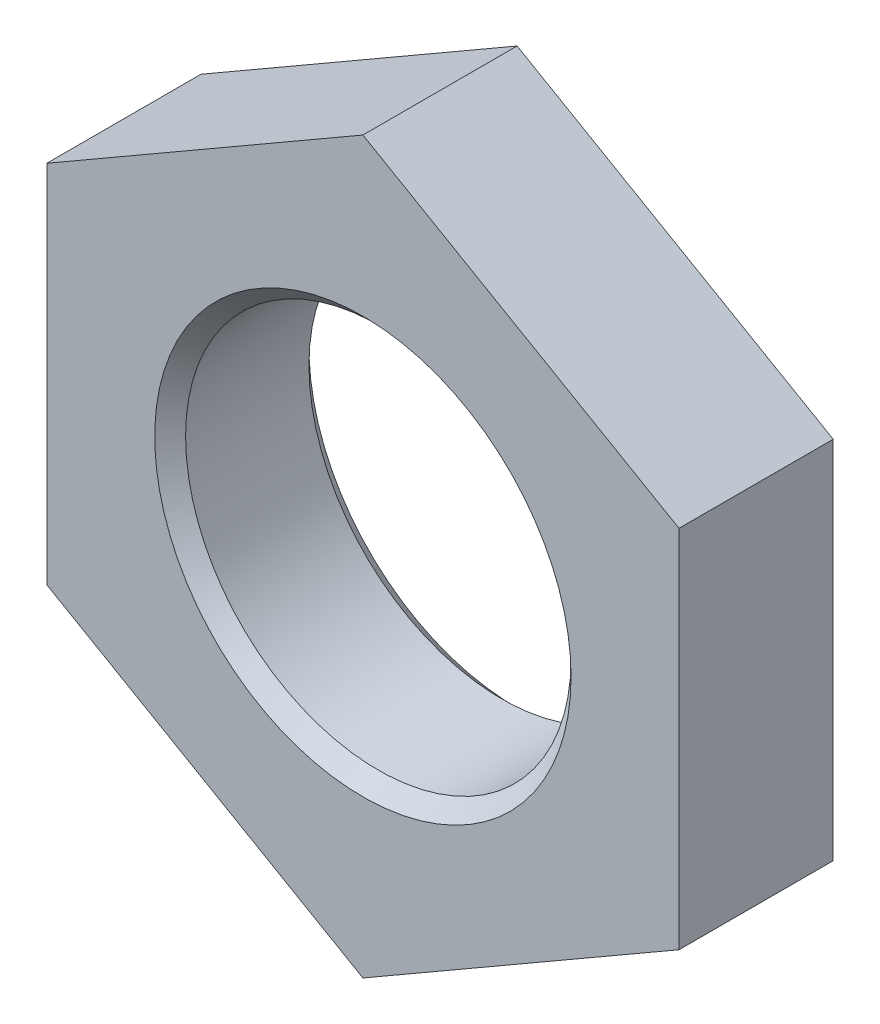
from build123d import *

# Parameters (mm, degrees)
SKETCH1_R           = 2.5
BOSS_EXTRUDE1_DEPTH = 2
CHAMFER1_SIZE       = 0.2


with BuildPart() as part:
    # Sketch1 → Boss-Extrude1 (new body)
    with BuildSketch(Plane.XY):
        Polygon((0, 4.734272207), (-4.1, 2.367136104), (-4.1, -2.367136104), (0, -4.734272207), (4.1, -2.367136104), (4.1, 2.367136104), align=None)
        Circle(SKETCH1_R, mode=Mode.SUBTRACT)
    extrude(amount=BOSS_EXTRUDE1_DEPTH)

    # Chamfer1
    chamfer1_edges = [part.edges().sort_by_distance(p)[0] for p in [
        (-2.5, 0, 0),
        (-2.5, 0, 2),
    ]]
    chamfer(chamfer1_edges, length=CHAMFER1_SIZE)


solid = part.part
